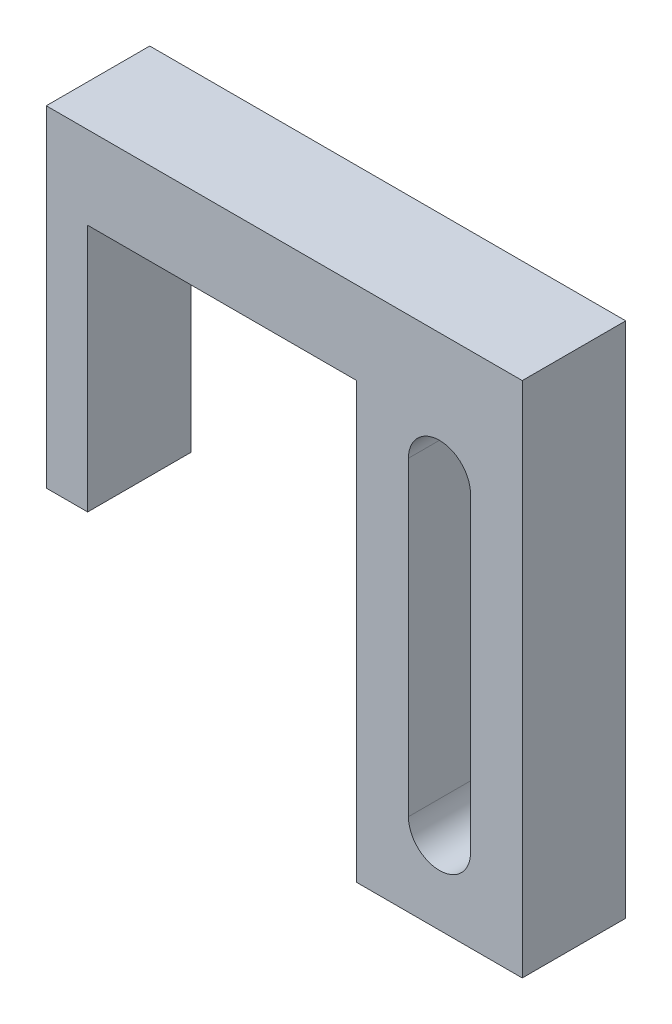
from build123d import *

# Parameters (mm, degrees)
SKETCH1_W           = 8
SKETCH1_H           = 25
BOSS_EXTRUDE6_DEPTH = 2.5
SKETCH8_W           = 15
SKETCH8_H           = 4
BOSS_EXTRUDE7_DEPTH = 5
SKETCH9_W           = 2
SKETCH9_H           = 5
BOSS_EXTRUDE8_DEPTH = 12
CUT_EXTRUDE1_DEPTH  = 6


with BuildPart() as part:
    # Sketch1 → Boss-Extrude6 (new body, symmetric)
    with BuildSketch(Plane.XY):
        Rectangle(SKETCH1_W, SKETCH1_H)
    extrude(amount=BOSS_EXTRUDE6_DEPTH, both=True)

    # Sketch8 → Boss-Extrude7 (add)
    with BuildSketch(Plane.XY.offset(2.5)):
        with Locations((-11.5, 10.5)):
            Rectangle(SKETCH8_W, SKETCH8_H)
    extrude(amount=-BOSS_EXTRUDE7_DEPTH)

    # Sketch9 → Boss-Extrude8 (add)
    with BuildSketch(Plane.XZ.offset(-8.5)):
        with Locations((-18, 0)):
            Rectangle(SKETCH9_W, SKETCH9_H)
    extrude(amount=BOSS_EXTRUDE8_DEPTH)

    # Sketch10 → Cut-Extrude1 (cut, through all)
    with BuildSketch(Plane.XY.offset(2.5)):
        with BuildLine():
            Line((1.5, 6.5), (1.5, -8.5))
            ThreePointArc((1.5, -8.5), (0, -10), (-1.5, -8.5))
            Line((-1.5, -8.5), (-1.5, 6.5))
            ThreePointArc((-1.5, 6.5), (0, 8), (1.5, 6.5))
        make_face()
    extrude(amount=-CUT_EXTRUDE1_DEPTH, mode=Mode.SUBTRACT)


solid = part.part
